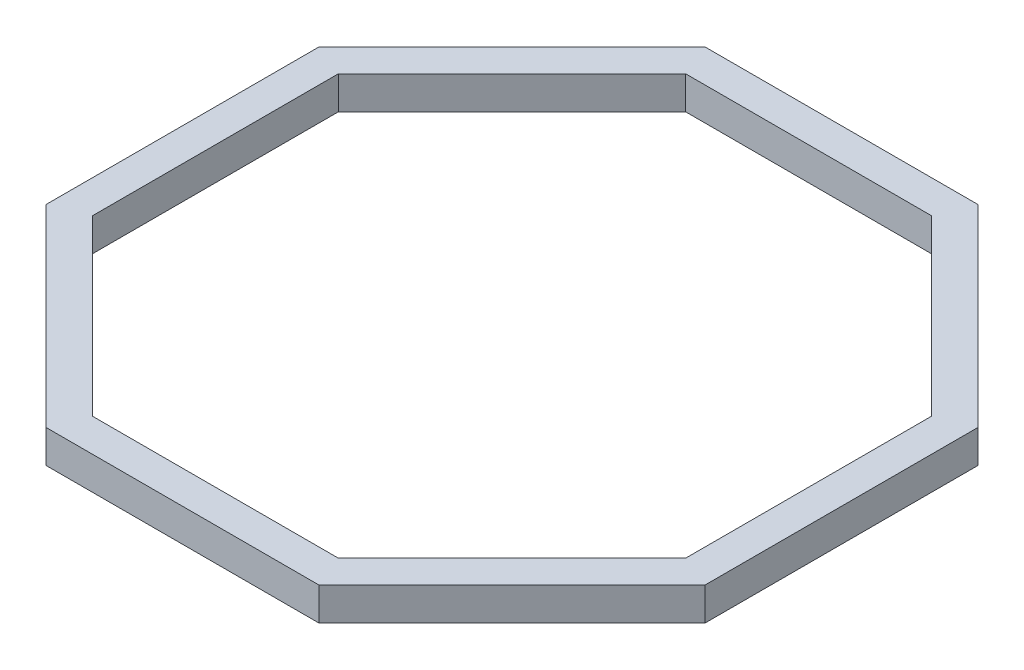
from build123d import *

# Parameters (mm, degrees)
SALIENTE_EXTRUIR1_DEPTH = 30


with BuildPart() as part:
    # Croquis1 → Saliente-Extruir1 (new body)
    with BuildSketch(Plane(origin=(0, 0, 0), x_dir=(1, 0, 0), z_dir=(0, 1, 0))):
        Polygon((300, -124.264068712), (300, 124.264068712), (124.264068712, 300), (-124.264068712, 300), (-300, 124.264068712), (-300, -124.264068712), (-124.264068712, -300), (124.264068712, -300), align=None)
        Polygon((270, -111.837661841), (270, 111.837661841), (111.837661841, 270), (-111.837661841, 270), (-270, 111.837661841), (-270, -111.837661841), (-111.837661841, -270), (111.837661841, -270), align=None, mode=Mode.SUBTRACT)
    extrude(amount=SALIENTE_EXTRUIR1_DEPTH)


solid = part.part
